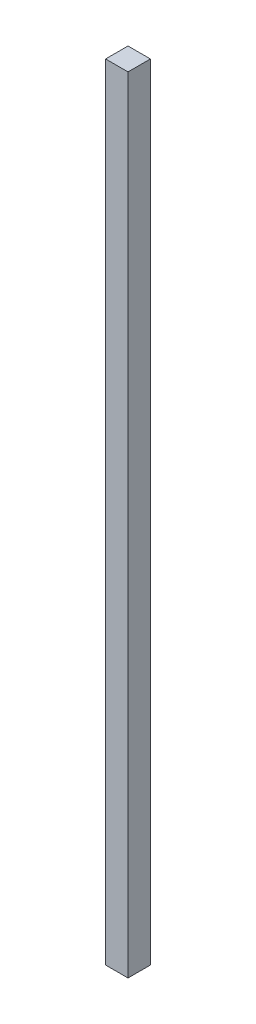
from build123d import *

# Parameters (mm, degrees)
SKETCH1_W           = 10
SKETCH1_H           = 10
BOSS_EXTRUDE1_DEPTH = 350


with BuildPart() as part:
    # Sketch1 → Boss-Extrude1 (new body)
    with BuildSketch(Plane(origin=(0, 0, 0), x_dir=(1, 0, 0), z_dir=(0, 1, 0))):
        Rectangle(SKETCH1_W, SKETCH1_H)
    extrude(amount=BOSS_EXTRUDE1_DEPTH)


solid = part.part
